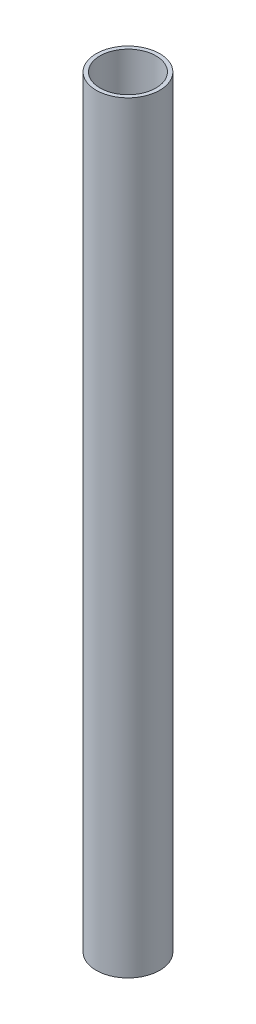
from build123d import *

# Parameters (mm, degrees)
SKETCH1_R           = 6.35
SKETCH1_R_2         = 5.588
BOSS_EXTRUDE1_DEPTH = 152.4


with BuildPart() as part:
    # Sketch1 → Boss-Extrude1 (new body)
    with BuildSketch(Plane(origin=(0, 0, 0), x_dir=(1, 0, 0), z_dir=(0, 1, 0))):
        Circle(SKETCH1_R)
        Circle(SKETCH1_R_2, mode=Mode.SUBTRACT)
    extrude(amount=BOSS_EXTRUDE1_DEPTH)


solid = part.part
